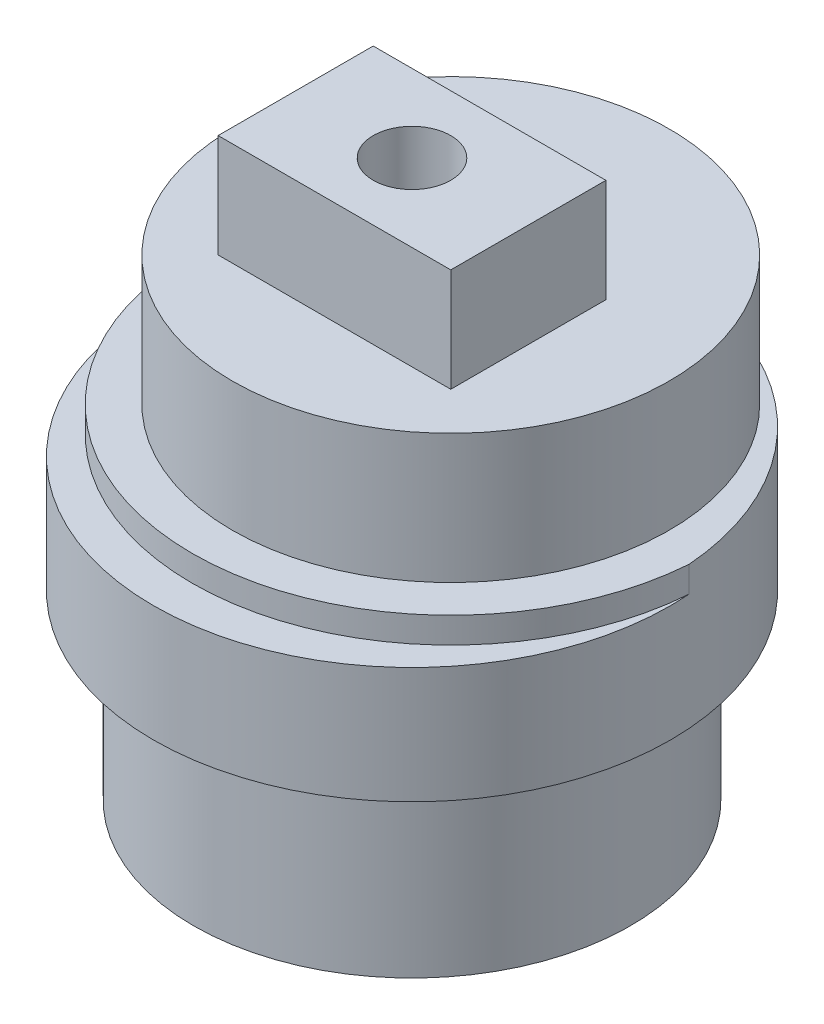
from build123d import *

# Parameters (mm, degrees)
SKETCH1_R           = 8.45
BOSS_EXTRUDE1_DEPTH = 7
SKETCH2_R           = 10
BOSS_EXTRUDE2_DEPTH = 4.5
SKETCH3_R           = 8.45
BOSS_EXTRUDE3_DEPTH = 6
SKETCH4_R           = 8.45
BOSS_EXTRUDE4_DEPTH = 1
SKETCH5_W           = 9
SKETCH5_H           = 6
BOSS_EXTRUDE5_DEPTH = 4
SKETCH6_R           = 1.5
CUT_EXTRUDE1_DEPTH  = 8
CUT_EXTRUDE4_DEPTH  = 10
CHAMFER1_SIZE       = 1


with BuildPart() as part:
    # Sketch1 → Boss-Extrude1 (new body)
    with BuildSketch(Plane(origin=(0, 0, 0), x_dir=(1, 0, 0), z_dir=(0, 1, 0))):
        Circle(SKETCH1_R)
    extrude(amount=BOSS_EXTRUDE1_DEPTH)

    # Sketch2 → Boss-Extrude2 (add)
    with BuildSketch(Plane(origin=(0, 7, 0), x_dir=(1, 0, 0), z_dir=(0, 1, 0))):
        Circle(SKETCH2_R)
    extrude(amount=BOSS_EXTRUDE2_DEPTH)

    # Sketch3 → Boss-Extrude3 (add)
    with BuildSketch(Plane(origin=(0, 11.5, 0), x_dir=(1, 0, 0), z_dir=(0, 1, 0))):
        with Locations((0, 1.5)):
            Circle(SKETCH3_R)
    extrude(amount=BOSS_EXTRUDE3_DEPTH)

    # Sketch4 → Boss-Extrude4 (add)
    with BuildSketch(Plane(origin=(0, 11.5, 0), x_dir=(1, 0, 0), z_dir=(0, 1, 0))):
        with BuildLine():
            ThreePointArc((9.971835338, 0.75), (0, 10), (-9.971835338, 0.75))
            ThreePointArc((-9.971835338, 0.75), (0, -8.5), (9.971835338, 0.75))
        make_face()
        with Locations((0, 1.5)):
            Circle(SKETCH4_R, mode=Mode.SUBTRACT)
    extrude(amount=BOSS_EXTRUDE4_DEPTH)

    # Sketch5 → Boss-Extrude5 (add)
    with BuildSketch(Plane(origin=(0, 17.5, 0), x_dir=(1, 0, 0), z_dir=(0, 1, 0))):
        Rectangle(SKETCH5_W, SKETCH5_H)
    extrude(amount=BOSS_EXTRUDE5_DEPTH)

    # Sketch6 → Cut-Extrude1 (cut)
    with BuildSketch(Plane(origin=(0, 21.5, 0), x_dir=(1, 0, 0), z_dir=(0, 1, 0))):
        Circle(SKETCH6_R)
    extrude(amount=-CUT_EXTRUDE1_DEPTH, mode=Mode.SUBTRACT)

    # Sketch9 → Cut-Extrude4 (cut)
    with BuildSketch(Plane(origin=(0, 0, 0), x_dir=(-1, 0, 0), z_dir=(0, -1, 0))):
        with BuildLine():
            Line((1.319090596, -1.15), (-1.319090596, -1.15))
            ThreePointArc((-1.319090596, -1.15), (0, 1.75), (1.319090596, -1.15))
        make_face()
    extrude(amount=-CUT_EXTRUDE4_DEPTH, mode=Mode.SUBTRACT)

    # Chamfer1
    chamfer1_edges = [part.edges().sort_by_distance(p)[0] for p in [
        (0, 0, -1.75),
        (0, 0, 1.15),
    ]]
    chamfer(chamfer1_edges, length=CHAMFER1_SIZE)


solid = part.part
